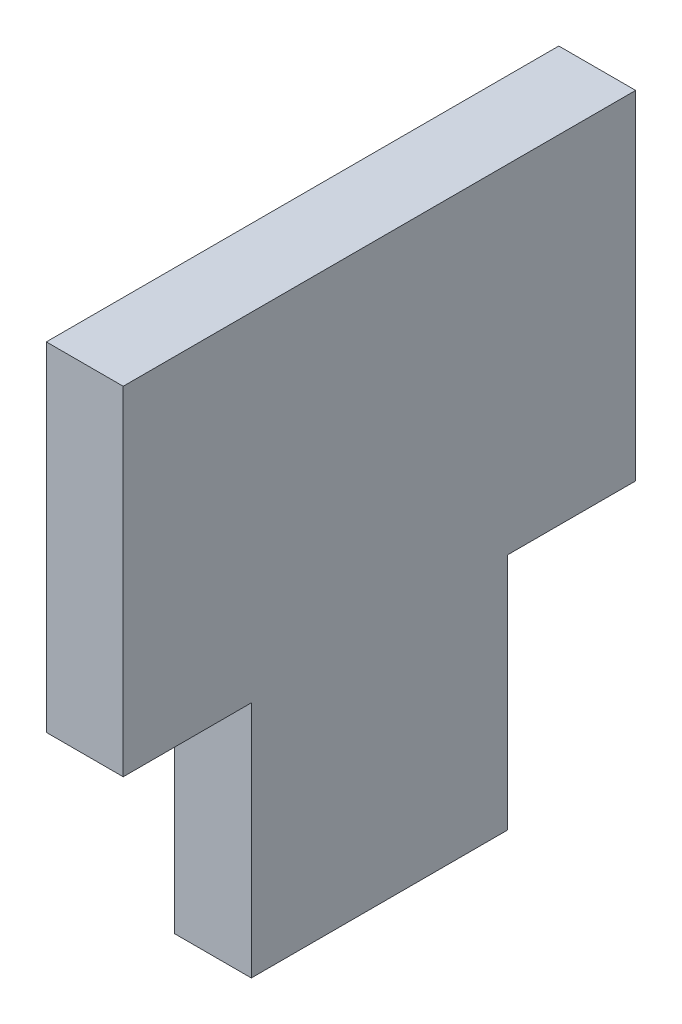
from build123d import *

# Parameters (mm, degrees)
BOSS_EXTRUDE1_DEPTH = 3


with BuildPart() as part:
    # Sketch1 → Boss-Extrude1 (new body)
    with BuildSketch(Plane(origin=(0, 0, 0), x_dir=(0, 0, -1), z_dir=(1, 0, 0))):
        Polygon((-5, -6.6), (-5, -15.9), (5, -15.9), (5, -6.6), (10, -6.6), (10, 6.6), (-10, 6.6), (-10, -6.6), align=None)
    extrude(amount=BOSS_EXTRUDE1_DEPTH)


solid = part.part
